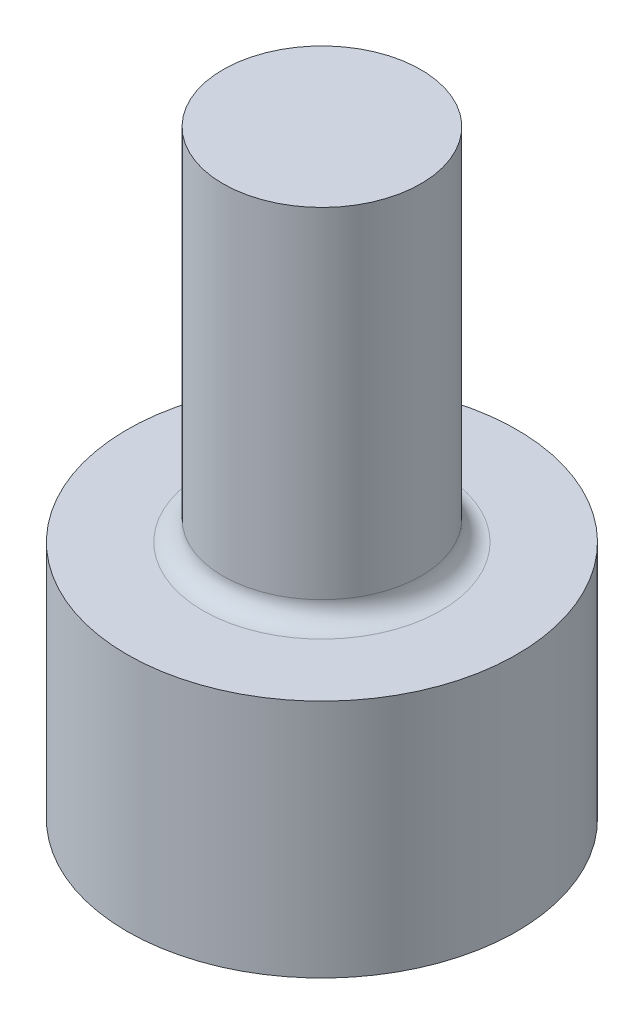
from build123d import *

# Parameters (mm, degrees)
SKETCH1_R           = 4.875
SKETCH1_R_2         = 1.875
BOSS_EXTRUDE1_DEPTH = 6
SKETCH2_R           = 2.475
BOSS_EXTRUDE2_DEPTH = 9
FILLET1_R           = 0.5


with BuildPart() as part:
    # Sketch1 → Boss-Extrude1 (new body)
    with BuildSketch(Plane(origin=(0, 0, 0), x_dir=(1, 0, 0), z_dir=(0, 1, 0))):
        Circle(SKETCH1_R)
        Circle(SKETCH1_R_2, mode=Mode.SUBTRACT)
    extrude(amount=BOSS_EXTRUDE1_DEPTH)

    # Sketch2 → Boss-Extrude2 (add)
    with BuildSketch(Plane(origin=(0, 6, 0), x_dir=(1, 0, 0), z_dir=(0, 1, 0))):
        Circle(SKETCH2_R)
    extrude(amount=BOSS_EXTRUDE2_DEPTH)

    # Fillet1
    fillet1_edges = [part.edges().sort_by_distance(p)[0] for p in [
        (-2.475, 6, 0),
    ]]
    fillet(fillet1_edges, radius=FILLET1_R)


solid = part.part
